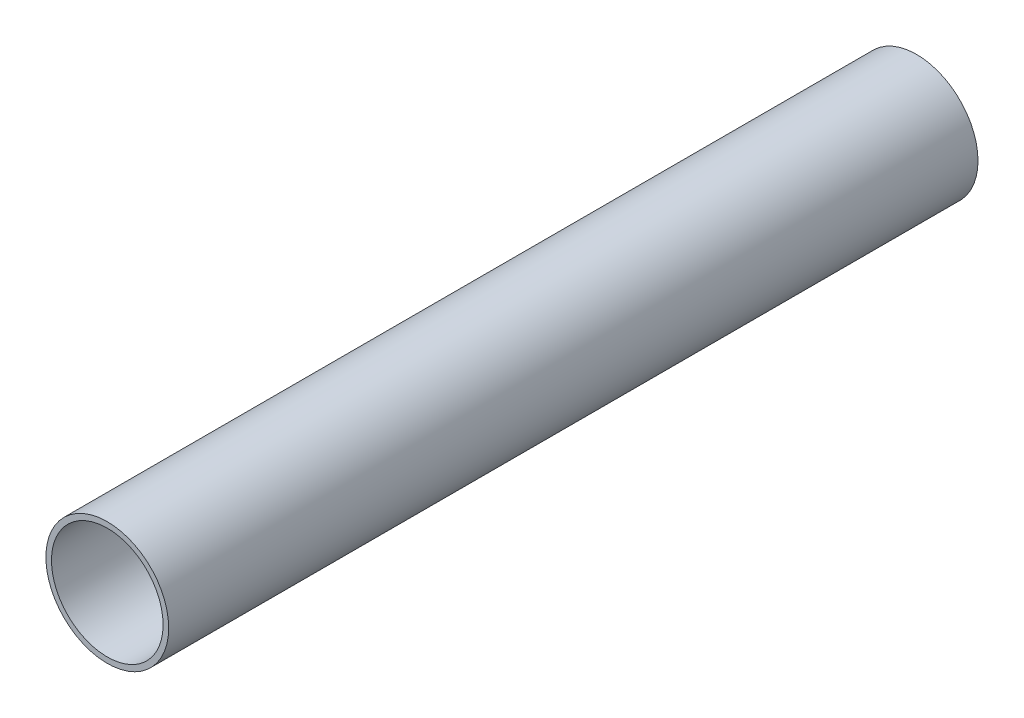
from build123d import *

# Parameters (mm, degrees)
SKETCH_1_R      = 11
SKETCH_1_R_2    = 10
EXTRUDE_1_DEPTH = 145


with BuildPart() as part:
    # Эскиз1 → Бобышка-Вытянуть1 (new body)
    with BuildSketch(Plane.XY):
        Circle(SKETCH_1_R)
        Circle(SKETCH_1_R_2, mode=Mode.SUBTRACT)
    extrude(amount=EXTRUDE_1_DEPTH)


solid = part.part
